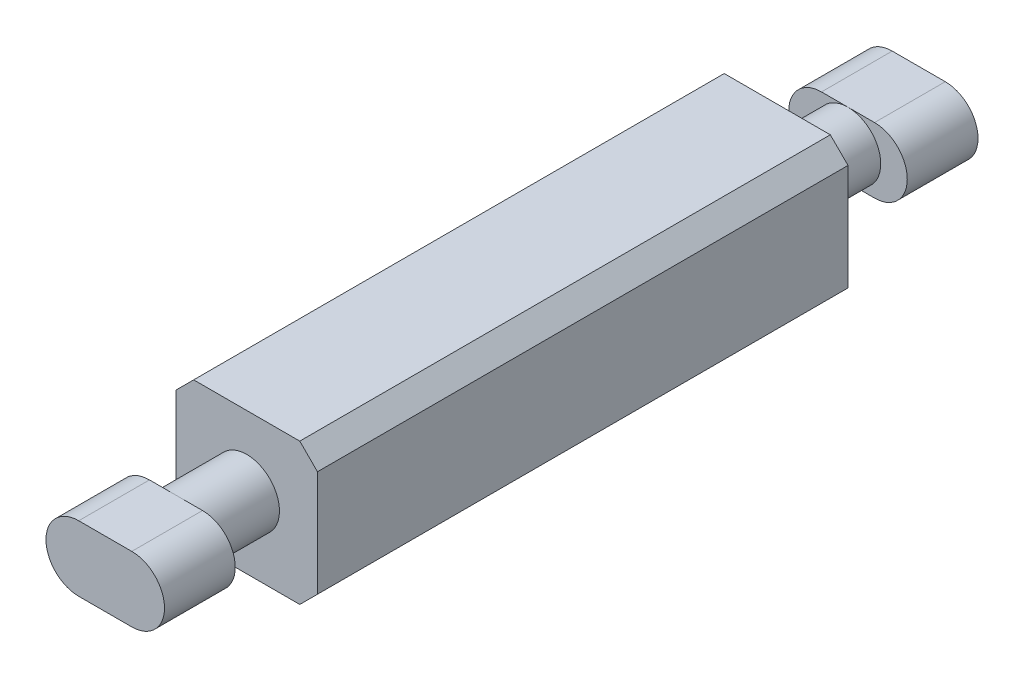
from build123d import *

# Parameters (mm, degrees)
SKETCH1_W                = 4
SKETCH1_H                = 15
BOSS_EXTRUDE1_DEPTH      = 4
SKETCH2_R                = 0.925
BOSS_EXTRUDE2_DEPTH      = 2
BOSS_EXTRUDE2_DEPTH_BACK = 17
CHAMFER1_SIZE            = 0.5
BOSS_EXTRUDE3_DEPTH      = 2
BOSS_EXTRUDE4_DEPTH      = 2


with BuildPart() as part:
    # Sketch1 → Boss-Extrude1 (new body)
    with BuildSketch(Plane(origin=(0, 0, 0), x_dir=(1, 0, 0), z_dir=(0, 1, 0))):
        Rectangle(SKETCH1_W, SKETCH1_H)
    extrude(amount=BOSS_EXTRUDE1_DEPTH)

    # Sketch2 → Boss-Extrude2 (add, two sides)
    with BuildSketch(Plane.XY.offset(7.5)) as boss_extrude2_sk:
        with Locations((0, 2)):
            Circle(SKETCH2_R)
    extrude(amount=BOSS_EXTRUDE2_DEPTH)
    extrude(boss_extrude2_sk.sketch, amount=-BOSS_EXTRUDE2_DEPTH_BACK)

    # Chamfer1
    chamfer1_edges = [part.edges().sort_by_distance(p)[0] for p in [
        (-2, 4, 0),
        (2, 4, 0),
        (-2, 0, 0),
        (2, 0, 0),
    ]]
    chamfer(chamfer1_edges, length=CHAMFER1_SIZE)

    # Sketch3 → Boss-Extrude3 (add)
    with BuildSketch(Plane.XY.offset(9.5)):
        with BuildLine():
            Line((-0.75, 2.925), (0.75, 2.925))
            ThreePointArc((0.75, 2.925), (1.675, 2), (0.75, 1.075))
            Line((0.75, 1.075), (-0.75, 1.075))
            ThreePointArc((-0.75, 1.075), (-1.675, 2), (-0.75, 2.925))
        make_face()
    extrude(amount=BOSS_EXTRUDE3_DEPTH)

    # Sketch4 → Boss-Extrude4 (add)
    with BuildSketch(Plane(origin=(0, 0, -9.5), x_dir=(-1, 0, 0), z_dir=(0, 0, -1))):
        with BuildLine():
            Line((-0.75, 2.925), (0.75, 2.925))
            ThreePointArc((0.75, 2.925), (1.675, 2), (0.75, 1.075))
            Line((0.75, 1.075), (-0.75, 1.075))
            ThreePointArc((-0.75, 1.075), (-1.675, 2), (-0.75, 2.925))
        make_face()
    extrude(amount=BOSS_EXTRUDE4_DEPTH)


solid = part.part
